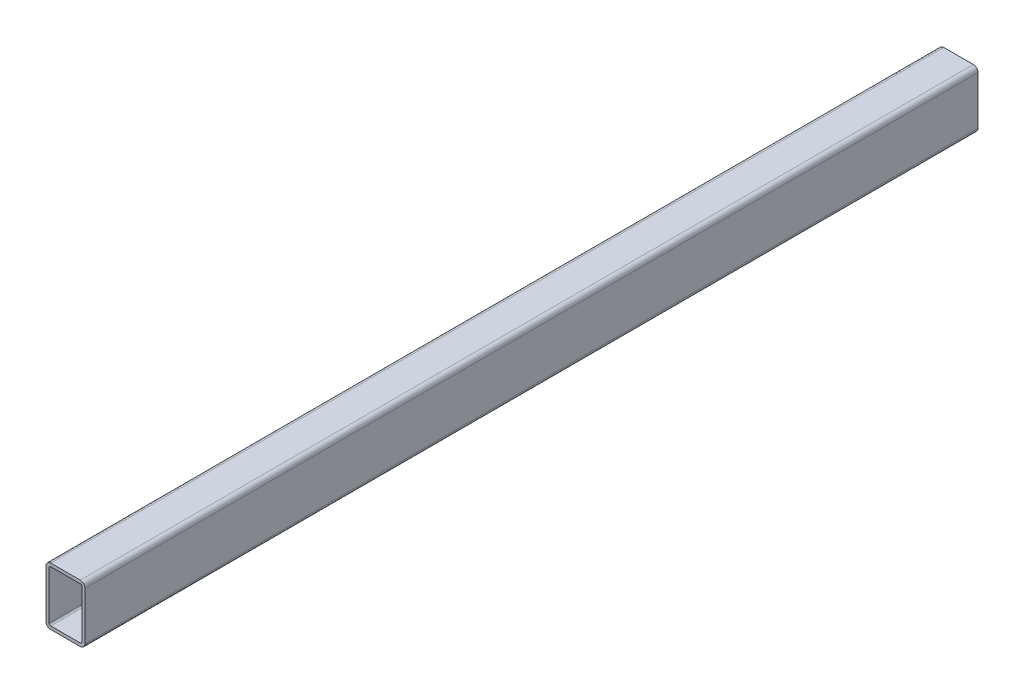
from build123d import *

# Parameters (mm, degrees)
EXTRUDE_THIN1_DEPTH = 287


with BuildPart() as part:
    # Sketch1 → Extrude-Thin1 (new body, symmetric)
    with BuildSketch(Plane.XY):
        with BuildLine():
            Line((-9.5, 37), (9.5, 37))
            ThreePointArc((9.5, 37), (11.621320344, 36.121320344), (12.5, 34))
            Line((12.5, 34), (12.5, 3))
            ThreePointArc((12.5, 3), (11.621320344, 0.878679656), (9.5, 0))
            Line((9.5, 0), (-9.5, 0))
            ThreePointArc((-9.5, 0), (-11.621320344, 0.878679656), (-12.5, 3))
            Line((-12.5, 3), (-12.5, 34))
            ThreePointArc((-12.5, 34), (-11.621320344, 36.121320344), (-9.5, 37))
        make_face()
        with BuildLine():
            Line((-9.5, 35), (9.5, 35))
            ThreePointArc((9.5, 35), (10.207106781, 34.707106781), (10.5, 34))
            Line((10.5, 34), (10.5, 3))
            ThreePointArc((10.5, 3), (10.207106781, 2.292893219), (9.5, 2))
            Line((9.5, 2), (-9.5, 2))
            ThreePointArc((-9.5, 2), (-10.207106781, 2.292893219), (-10.5, 3))
            Line((-10.5, 3), (-10.5, 34))
            ThreePointArc((-10.5, 34), (-10.207106781, 34.707106781), (-9.5, 35))
        make_face(mode=Mode.SUBTRACT)
    extrude(amount=EXTRUDE_THIN1_DEPTH, both=True)


solid = part.part
